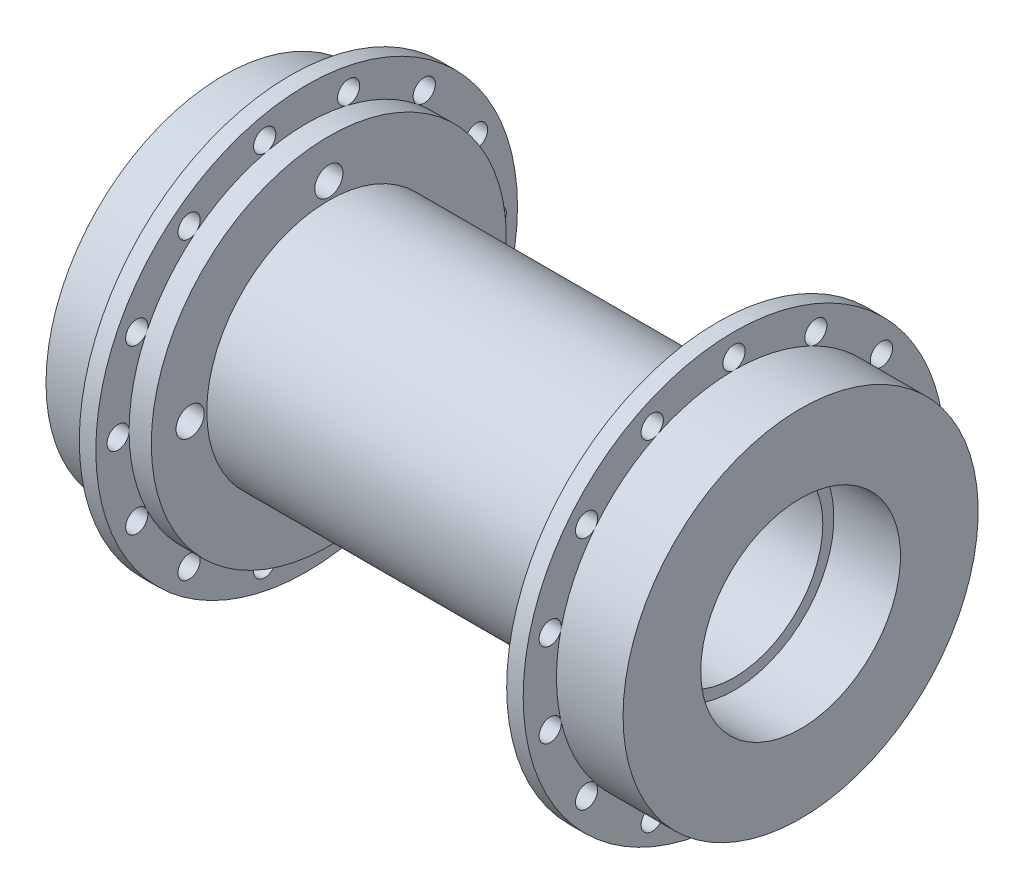
from build123d import *

# Parameters (mm, degrees)
F_10_32_TAPPED_HOLE1_D                    = 4.0386
F_10_32_TAPPED_HOLE1_DEPTH                = 15.0622
SKETCH4_W                                 = 1.5875
SKETCH4_H                                 = 2.3622
F_1_8_0_125000_DIAMETER_HOLE1_AT_2_COUNT  = 2
F_1_8_0_125000_DIAMETER_HOLE1_AT_2_PITCH  = 12.004915379
F_1_8_0_125000_DIAMETER_HOLE1_AT_3_COUNT  = 2
F_1_8_0_125000_DIAMETER_HOLE1_AT_3_PITCH  = 23.407854172
F_1_8_0_125000_DIAMETER_HOLE1_AT_4_COUNT  = 2
F_1_8_0_125000_DIAMETER_HOLE1_AT_4_PITCH  = 33.637025414
F_1_8_0_125000_DIAMETER_HOLE1_AT_5_COUNT  = 2
F_1_8_0_125000_DIAMETER_HOLE1_AT_5_PITCH  = 42.179495747
F_1_8_0_125000_DIAMETER_HOLE1_AT_6_COUNT  = 2
F_1_8_0_125000_DIAMETER_HOLE1_AT_6_PITCH  = 48.606910036
F_1_8_0_125000_DIAMETER_HOLE1_AT_7_COUNT  = 2
F_1_8_0_125000_DIAMETER_HOLE1_AT_7_PITCH  = 52.596970891
F_1_8_0_125000_DIAMETER_HOLE1_AT_8_COUNT  = 2
F_1_8_0_125000_DIAMETER_HOLE1_AT_8_PITCH  = 53.9496
F_1_8_0_125000_DIAMETER_HOLE1_AT_9_COUNT  = 2
F_1_8_0_125000_DIAMETER_HOLE1_AT_9_PITCH  = 52.596970891
F_1_8_0_125000_DIAMETER_HOLE1_AT_10_COUNT = 2
F_1_8_0_125000_DIAMETER_HOLE1_AT_10_PITCH = 48.606910036
F_1_8_0_125000_DIAMETER_HOLE1_AT_11_COUNT = 2
F_1_8_0_125000_DIAMETER_HOLE1_AT_11_PITCH = 42.179495747
F_1_8_0_125000_DIAMETER_HOLE1_AT_12_COUNT = 2
F_1_8_0_125000_DIAMETER_HOLE1_AT_12_PITCH = 33.637025414
F_1_8_0_125000_DIAMETER_HOLE1_AT_13_COUNT = 2
F_1_8_0_125000_DIAMETER_HOLE1_AT_13_PITCH = 23.407854172
F_1_8_0_125000_DIAMETER_HOLE1_AT_14_COUNT = 2
F_1_8_0_125000_DIAMETER_HOLE1_AT_14_PITCH = 12.004915379
SKETCH6_W                                 = 1.5875
SKETCH6_H                                 = 2.3622
F_1_8_0_125000_DIAMETER_HOLE2_AT_2_COUNT  = 2
F_1_8_0_125000_DIAMETER_HOLE2_AT_2_PITCH  = 12.004915379
F_1_8_0_125000_DIAMETER_HOLE2_AT_3_COUNT  = 2
F_1_8_0_125000_DIAMETER_HOLE2_AT_3_PITCH  = 23.407854172
F_1_8_0_125000_DIAMETER_HOLE2_AT_4_COUNT  = 2
F_1_8_0_125000_DIAMETER_HOLE2_AT_4_PITCH  = 33.637025414
F_1_8_0_125000_DIAMETER_HOLE2_AT_5_COUNT  = 2
F_1_8_0_125000_DIAMETER_HOLE2_AT_5_PITCH  = 42.179495747
F_1_8_0_125000_DIAMETER_HOLE2_AT_6_COUNT  = 2
F_1_8_0_125000_DIAMETER_HOLE2_AT_6_PITCH  = 48.606910036
F_1_8_0_125000_DIAMETER_HOLE2_AT_7_COUNT  = 2
F_1_8_0_125000_DIAMETER_HOLE2_AT_7_PITCH  = 52.596970891
F_1_8_0_125000_DIAMETER_HOLE2_AT_8_COUNT  = 2
F_1_8_0_125000_DIAMETER_HOLE2_AT_8_PITCH  = 53.9496
F_1_8_0_125000_DIAMETER_HOLE2_AT_9_COUNT  = 2
F_1_8_0_125000_DIAMETER_HOLE2_AT_9_PITCH  = 52.596970891
F_1_8_0_125000_DIAMETER_HOLE2_AT_10_COUNT = 2
F_1_8_0_125000_DIAMETER_HOLE2_AT_10_PITCH = 48.606910036
F_1_8_0_125000_DIAMETER_HOLE2_AT_11_COUNT = 2
F_1_8_0_125000_DIAMETER_HOLE2_AT_11_PITCH = 42.179495747
F_1_8_0_125000_DIAMETER_HOLE2_AT_12_COUNT = 2
F_1_8_0_125000_DIAMETER_HOLE2_AT_12_PITCH = 33.637025414
F_1_8_0_125000_DIAMETER_HOLE2_AT_13_COUNT = 2
F_1_8_0_125000_DIAMETER_HOLE2_AT_13_PITCH = 23.407854172
F_1_8_0_125000_DIAMETER_HOLE2_AT_14_COUNT = 2
F_1_8_0_125000_DIAMETER_HOLE2_AT_14_PITCH = 12.004915379


with BuildPart() as part:
    # Sketch1 → Revolve1 (revolve)
    with BuildSketch(Plane.XY):
        Polygon((41.275, 25.4), (41.275, 14.2875), (31.75, 14.2875), (31.75, 12.7), (-31.75, 12.7), (-31.75, 14.2875), (-41.275, 14.2875), (-41.275, 25.4), (-31.75, 25.4), (-31.75, 30.1625), (-29.3878, 30.1625), (-29.3878, 25.4), (-26.2128, 25.4), (-26.2128, 17.4625), (26.2128, 17.4625), (26.2128, 25.4), (29.3878, 25.4), (29.3878, 30.1625), (31.75, 30.1625), (31.75, 25.4), align=None)
    revolve(axis=Axis((-48.698417792, 0, 0), (1, 0, 0)))

    # #10-32 Tapped Hole1
    with Locations(Plane.ZY.offset(41.275)):
        with Locations((19.84375, 0), (0, 19.84375), (-19.84375, 0), (0, -19.84375)):
            Hole(F_10_32_TAPPED_HOLE1_D / 2, depth=F_10_32_TAPPED_HOLE1_DEPTH)

    # Sketch4 → 1/8 (0.125000) Diameter Hole1 (revolve, cut)
    with BuildSketch(Plane(origin=(31.75, 26.9748, 0), x_dir=(0, 0, -1), z_dir=(0, 1, 0))):
        with Locations((0.79375, 1.1811)):
            Rectangle(SKETCH4_W, SKETCH4_H)
    f_1_8_0_125000_diameter_hole1 = revolve(axis=Axis((38.1, 26.9748, 0), (-1, 0, 0)), mode=Mode.SUBTRACT)

    # 1/8 (0.125000) Diameter Hole1 at 2: 1/8 (0.125000) Diameter Hole1 ×2
    with Locations(*[Vector(0, -0.222520934, -0.974927912) * (i * F_1_8_0_125000_DIAMETER_HOLE1_AT_2_PITCH) for i in range(1, F_1_8_0_125000_DIAMETER_HOLE1_AT_2_COUNT)]):
        add(f_1_8_0_125000_diameter_hole1, mode=Mode.SUBTRACT)

    # 1/8 (0.125000) Diameter Hole1 at 3: 1/8 (0.125000) Diameter Hole1 ×2
    with Locations(*[Vector(0, -0.433883739, -0.900968868) * (i * F_1_8_0_125000_DIAMETER_HOLE1_AT_3_PITCH) for i in range(1, F_1_8_0_125000_DIAMETER_HOLE1_AT_3_COUNT)]):
        add(f_1_8_0_125000_diameter_hole1, mode=Mode.SUBTRACT)

    # 1/8 (0.125000) Diameter Hole1 at 4: 1/8 (0.125000) Diameter Hole1 ×2
    with Locations(*[Vector(0, -0.623489802, -0.781831482) * (i * F_1_8_0_125000_DIAMETER_HOLE1_AT_4_PITCH) for i in range(1, F_1_8_0_125000_DIAMETER_HOLE1_AT_4_COUNT)]):
        add(f_1_8_0_125000_diameter_hole1, mode=Mode.SUBTRACT)

    # 1/8 (0.125000) Diameter Hole1 at 5: 1/8 (0.125000) Diameter Hole1 ×2
    with Locations(*[Vector(0, -0.781831482, -0.623489802) * (i * F_1_8_0_125000_DIAMETER_HOLE1_AT_5_PITCH) for i in range(1, F_1_8_0_125000_DIAMETER_HOLE1_AT_5_COUNT)]):
        add(f_1_8_0_125000_diameter_hole1, mode=Mode.SUBTRACT)

    # 1/8 (0.125000) Diameter Hole1 at 6: 1/8 (0.125000) Diameter Hole1 ×2
    with Locations(*[Vector(0, -0.900968868, -0.433883739) * (i * F_1_8_0_125000_DIAMETER_HOLE1_AT_6_PITCH) for i in range(1, F_1_8_0_125000_DIAMETER_HOLE1_AT_6_COUNT)]):
        add(f_1_8_0_125000_diameter_hole1, mode=Mode.SUBTRACT)

    # 1/8 (0.125000) Diameter Hole1 at 7: 1/8 (0.125000) Diameter Hole1 ×2
    with Locations(*[Vector(0, -0.974927912, -0.222520934) * (i * F_1_8_0_125000_DIAMETER_HOLE1_AT_7_PITCH) for i in range(1, F_1_8_0_125000_DIAMETER_HOLE1_AT_7_COUNT)]):
        add(f_1_8_0_125000_diameter_hole1, mode=Mode.SUBTRACT)

    # 1/8 (0.125000) Diameter Hole1 at 8: 1/8 (0.125000) Diameter Hole1 ×2
    with Locations(*[(0, -i * F_1_8_0_125000_DIAMETER_HOLE1_AT_8_PITCH, 0) for i in range(1, F_1_8_0_125000_DIAMETER_HOLE1_AT_8_COUNT)]):
        add(f_1_8_0_125000_diameter_hole1, mode=Mode.SUBTRACT)

    # 1/8 (0.125000) Diameter Hole1 at 9: 1/8 (0.125000) Diameter Hole1 ×2
    with Locations(*[Vector(0, -0.974927912, 0.222520934) * (i * F_1_8_0_125000_DIAMETER_HOLE1_AT_9_PITCH) for i in range(1, F_1_8_0_125000_DIAMETER_HOLE1_AT_9_COUNT)]):
        add(f_1_8_0_125000_diameter_hole1, mode=Mode.SUBTRACT)

    # 1/8 (0.125000) Diameter Hole1 at 10: 1/8 (0.125000) Diameter Hole1 ×2
    with Locations(*[Vector(0, -0.900968868, 0.433883739) * (i * F_1_8_0_125000_DIAMETER_HOLE1_AT_10_PITCH) for i in range(1, F_1_8_0_125000_DIAMETER_HOLE1_AT_10_COUNT)]):
        add(f_1_8_0_125000_diameter_hole1, mode=Mode.SUBTRACT)

    # 1/8 (0.125000) Diameter Hole1 at 11: 1/8 (0.125000) Diameter Hole1 ×2
    with Locations(*[Vector(0, -0.781831482, 0.623489802) * (i * F_1_8_0_125000_DIAMETER_HOLE1_AT_11_PITCH) for i in range(1, F_1_8_0_125000_DIAMETER_HOLE1_AT_11_COUNT)]):
        add(f_1_8_0_125000_diameter_hole1, mode=Mode.SUBTRACT)

    # 1/8 (0.125000) Diameter Hole1 at 12: 1/8 (0.125000) Diameter Hole1 ×2
    with Locations(*[Vector(0, -0.623489802, 0.781831482) * (i * F_1_8_0_125000_DIAMETER_HOLE1_AT_12_PITCH) for i in range(1, F_1_8_0_125000_DIAMETER_HOLE1_AT_12_COUNT)]):
        add(f_1_8_0_125000_diameter_hole1, mode=Mode.SUBTRACT)

    # 1/8 (0.125000) Diameter Hole1 at 13: 1/8 (0.125000) Diameter Hole1 ×2
    with Locations(*[Vector(0, -0.433883739, 0.900968868) * (i * F_1_8_0_125000_DIAMETER_HOLE1_AT_13_PITCH) for i in range(1, F_1_8_0_125000_DIAMETER_HOLE1_AT_13_COUNT)]):
        add(f_1_8_0_125000_diameter_hole1, mode=Mode.SUBTRACT)

    # 1/8 (0.125000) Diameter Hole1 at 14: 1/8 (0.125000) Diameter Hole1 ×2
    with Locations(*[Vector(0, -0.222520934, 0.974927912) * (i * F_1_8_0_125000_DIAMETER_HOLE1_AT_14_PITCH) for i in range(1, F_1_8_0_125000_DIAMETER_HOLE1_AT_14_COUNT)]):
        add(f_1_8_0_125000_diameter_hole1, mode=Mode.SUBTRACT)

    # Sketch6 → 1/8 (0.125000) Diameter Hole2 (revolve, cut)
    with BuildSketch(Plane(origin=(-31.75, 0, -26.9748), x_dir=(0, 0, 1), z_dir=(0, 1, 0))):
        with Locations((0.79375, 1.1811)):
            Rectangle(SKETCH6_W, SKETCH6_H)
    f_1_8_0_125000_diameter_hole2 = revolve(axis=Axis((-38.1, 0, -26.9748), (1, 0, 0)), mode=Mode.SUBTRACT)

    # 1/8 (0.125000) Diameter Hole2 at 2: 1/8 (0.125000) Diameter Hole2 ×2
    with Locations(*[Vector(0, 0.974927912, 0.222520934) * (i * F_1_8_0_125000_DIAMETER_HOLE2_AT_2_PITCH) for i in range(1, F_1_8_0_125000_DIAMETER_HOLE2_AT_2_COUNT)]):
        add(f_1_8_0_125000_diameter_hole2, mode=Mode.SUBTRACT)

    # 1/8 (0.125000) Diameter Hole2 at 3: 1/8 (0.125000) Diameter Hole2 ×2
    with Locations(*[Vector(0, 0.900968868, 0.433883739) * (i * F_1_8_0_125000_DIAMETER_HOLE2_AT_3_PITCH) for i in range(1, F_1_8_0_125000_DIAMETER_HOLE2_AT_3_COUNT)]):
        add(f_1_8_0_125000_diameter_hole2, mode=Mode.SUBTRACT)

    # 1/8 (0.125000) Diameter Hole2 at 4: 1/8 (0.125000) Diameter Hole2 ×2
    with Locations(*[Vector(0, 0.781831482, 0.623489802) * (i * F_1_8_0_125000_DIAMETER_HOLE2_AT_4_PITCH) for i in range(1, F_1_8_0_125000_DIAMETER_HOLE2_AT_4_COUNT)]):
        add(f_1_8_0_125000_diameter_hole2, mode=Mode.SUBTRACT)

    # 1/8 (0.125000) Diameter Hole2 at 5: 1/8 (0.125000) Diameter Hole2 ×2
    with Locations(*[Vector(0, 0.623489802, 0.781831482) * (i * F_1_8_0_125000_DIAMETER_HOLE2_AT_5_PITCH) for i in range(1, F_1_8_0_125000_DIAMETER_HOLE2_AT_5_COUNT)]):
        add(f_1_8_0_125000_diameter_hole2, mode=Mode.SUBTRACT)

    # 1/8 (0.125000) Diameter Hole2 at 6: 1/8 (0.125000) Diameter Hole2 ×2
    with Locations(*[Vector(0, 0.433883739, 0.900968868) * (i * F_1_8_0_125000_DIAMETER_HOLE2_AT_6_PITCH) for i in range(1, F_1_8_0_125000_DIAMETER_HOLE2_AT_6_COUNT)]):
        add(f_1_8_0_125000_diameter_hole2, mode=Mode.SUBTRACT)

    # 1/8 (0.125000) Diameter Hole2 at 7: 1/8 (0.125000) Diameter Hole2 ×2
    with Locations(*[Vector(0, 0.222520934, 0.974927912) * (i * F_1_8_0_125000_DIAMETER_HOLE2_AT_7_PITCH) for i in range(1, F_1_8_0_125000_DIAMETER_HOLE2_AT_7_COUNT)]):
        add(f_1_8_0_125000_diameter_hole2, mode=Mode.SUBTRACT)

    # 1/8 (0.125000) Diameter Hole2 at 8: 1/8 (0.125000) Diameter Hole2 ×2
    with Locations(*[(0, 0, i * F_1_8_0_125000_DIAMETER_HOLE2_AT_8_PITCH) for i in range(1, F_1_8_0_125000_DIAMETER_HOLE2_AT_8_COUNT)]):
        add(f_1_8_0_125000_diameter_hole2, mode=Mode.SUBTRACT)

    # 1/8 (0.125000) Diameter Hole2 at 9: 1/8 (0.125000) Diameter Hole2 ×2
    with Locations(*[Vector(0, -0.222520934, 0.974927912) * (i * F_1_8_0_125000_DIAMETER_HOLE2_AT_9_PITCH) for i in range(1, F_1_8_0_125000_DIAMETER_HOLE2_AT_9_COUNT)]):
        add(f_1_8_0_125000_diameter_hole2, mode=Mode.SUBTRACT)

    # 1/8 (0.125000) Diameter Hole2 at 10: 1/8 (0.125000) Diameter Hole2 ×2
    with Locations(*[Vector(0, -0.433883739, 0.900968868) * (i * F_1_8_0_125000_DIAMETER_HOLE2_AT_10_PITCH) for i in range(1, F_1_8_0_125000_DIAMETER_HOLE2_AT_10_COUNT)]):
        add(f_1_8_0_125000_diameter_hole2, mode=Mode.SUBTRACT)

    # 1/8 (0.125000) Diameter Hole2 at 11: 1/8 (0.125000) Diameter Hole2 ×2
    with Locations(*[Vector(0, -0.623489802, 0.781831482) * (i * F_1_8_0_125000_DIAMETER_HOLE2_AT_11_PITCH) for i in range(1, F_1_8_0_125000_DIAMETER_HOLE2_AT_11_COUNT)]):
        add(f_1_8_0_125000_diameter_hole2, mode=Mode.SUBTRACT)

    # 1/8 (0.125000) Diameter Hole2 at 12: 1/8 (0.125000) Diameter Hole2 ×2
    with Locations(*[Vector(0, -0.781831482, 0.623489802) * (i * F_1_8_0_125000_DIAMETER_HOLE2_AT_12_PITCH) for i in range(1, F_1_8_0_125000_DIAMETER_HOLE2_AT_12_COUNT)]):
        add(f_1_8_0_125000_diameter_hole2, mode=Mode.SUBTRACT)

    # 1/8 (0.125000) Diameter Hole2 at 13: 1/8 (0.125000) Diameter Hole2 ×2
    with Locations(*[Vector(0, -0.900968868, 0.433883739) * (i * F_1_8_0_125000_DIAMETER_HOLE2_AT_13_PITCH) for i in range(1, F_1_8_0_125000_DIAMETER_HOLE2_AT_13_COUNT)]):
        add(f_1_8_0_125000_diameter_hole2, mode=Mode.SUBTRACT)

    # 1/8 (0.125000) Diameter Hole2 at 14: 1/8 (0.125000) Diameter Hole2 ×2
    with Locations(*[Vector(0, -0.974927912, 0.222520934) * (i * F_1_8_0_125000_DIAMETER_HOLE2_AT_14_PITCH) for i in range(1, F_1_8_0_125000_DIAMETER_HOLE2_AT_14_COUNT)]):
        add(f_1_8_0_125000_diameter_hole2, mode=Mode.SUBTRACT)


solid = part.part
